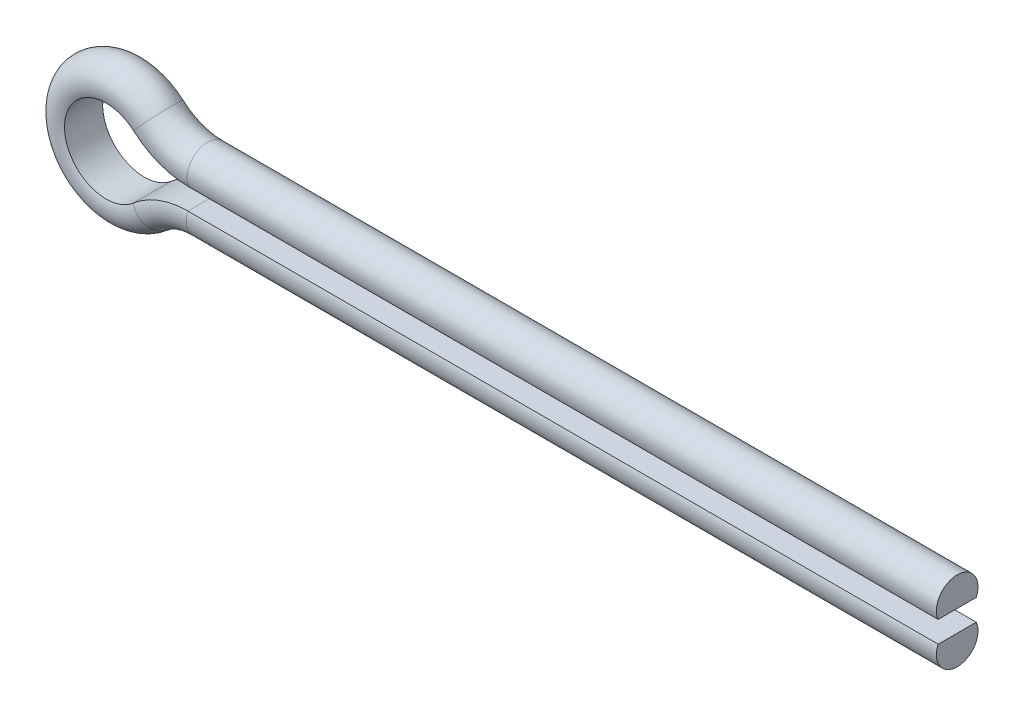
from build123d import *


with BuildPart() as part:
    # Sweep1: sweep along a path in Sketch1
    with BuildLine(Plane.XY) as sweep1_path:
        Line((0, 0), (-90.078432584, 0))
        ThreePointArc((-90.078432584, 0), (-93.613966489, 0.645856533), (-96.692810861, 2.5))
        ThreePointArc((-96.692810861, 2.5), (-104.999960358, -1.230089771), (-96.72278085, -5.026219624))
        ThreePointArc((-96.72278085, -5.026219624), (-93.666599798, -3.210510909), (-90.168342551, -2.578658871))
        Line((-90.168342551, -2.578658871), (0, -2.578658871))
    # Sketch2 → Sweep1 (sweep)
    with BuildSketch(Plane(origin=(0, 0, 0), x_dir=(0, 0, -1), z_dir=(1, 0, 0))):
        with BuildLine():
            Line((2.291287847, 0), (-2.291287847, 0))
            ThreePointArc((-2.291287847, 0), (0, 3.5), (2.291287847, 0))
        make_face()
    sweep(path=sweep1_path.line)


solid = part.part
